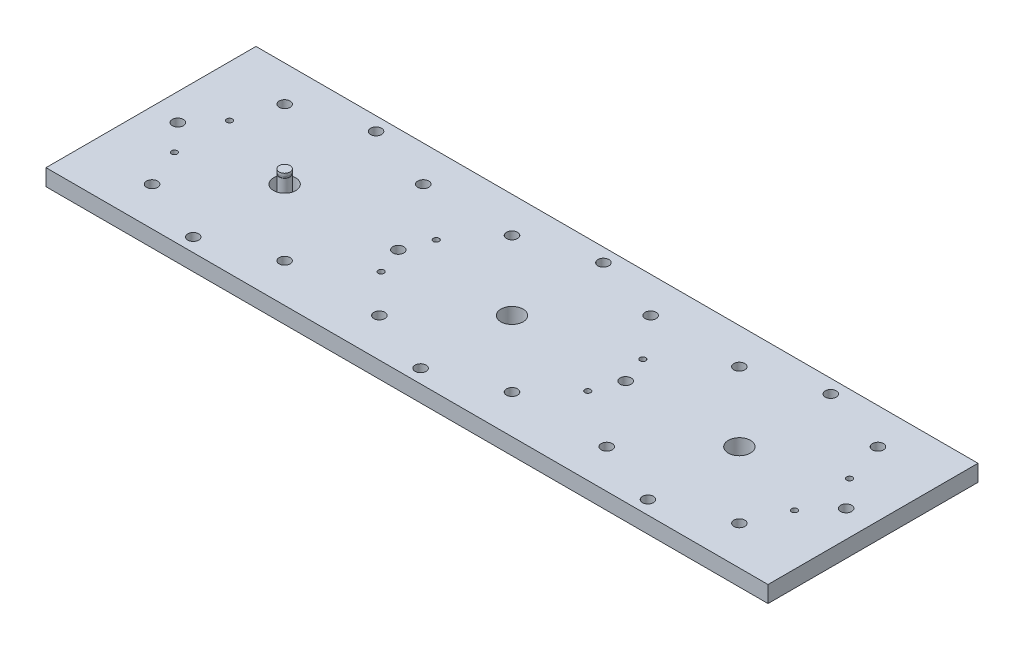
from build123d import *

# Parameters (mm, degrees)
SKETCH1_W                                           = 524
SKETCH1_H                                           = 152.4
SKETCH1_R                                           = 8.05
BOSS_EXTRUDE1_DEPTH                                 = 6
M5_TAPPED_HOLE1_D                                   = 4.2
CBORE_FOR_M4_HEX_SOCKET_HEAD_CAP_SCREW1_D           = 4.5
CBORE_FOR_M4_HEX_SOCKET_HEAD_CAP_SCREW1_CBORE_D     = 8
CBORE_FOR_M4_HEX_SOCKET_HEAD_CAP_SCREW1_CBORE_DEPTH = 9.4


with BuildPart() as part:
    # Sketch1 → Boss-Extrude1 (new body, symmetric)
    with BuildSketch(Plane(origin=(0, 0, 0), x_dir=(1, 0, 0), z_dir=(0, 1, 0))):
        Rectangle(SKETCH1_W, SKETCH1_H)
        with Locations((-165, 0)):
            Circle(SKETCH1_R, mode=Mode.SUBTRACT)
        Circle(SKETCH1_R, mode=Mode.SUBTRACT)
        with Locations((165, 0)):
            Circle(SKETCH1_R, mode=Mode.SUBTRACT)
    extrude(amount=BOSS_EXTRUDE1_DEPTH, both=True)

    # M5 Tapped Hole1 (through all)
    with Locations(Plane(origin=(0, 6, 0), x_dir=(1, 0, 0), z_dir=(0, 1, 0))):
        with Locations((-75, 20), (-225, 20), (-225, -20), (-75, -20), (225, 20), (225, -20), (75, -20), (75, 20)):
            Hole(M5_TAPPED_HOLE1_D / 2)

    # CBORE for M4 Hex Socket Head Cap Screw1 (through all)
    with Locations(Plane(origin=(0, 6, 0), x_dir=(1, 0, 0), z_dir=(0, 1, 0))):
        with Locations((-242.5, 0), (-215.297302762, 50.297302762), (-213.11851323, -48.11851323), (-165, -66.337901802), (-165, 66.338078988), (-114.702697238, 50.297302762), (-116.88148677, -48.11851323), (-82.5, 0), (-48.11851323, -48.11851323), (-50.297302762, 50.297302762), (0, 66.338078988), (0, -66.337901802), (48.11851323, -48.11851323), (50.297302762, 50.297302762), (82.5, 0), (114.702697238, 50.297302762), (116.88148677, -48.11851323), (165, -66.337901802), (165, 66.338078988), (215.297302762, 50.297302762), (213.11851323, -48.11851323), (242.5, 0)):
            CounterBoreHole(CBORE_FOR_M4_HEX_SOCKET_HEAD_CAP_SCREW1_D / 2, CBORE_FOR_M4_HEX_SOCKET_HEAD_CAP_SCREW1_CBORE_D / 2, CBORE_FOR_M4_HEX_SOCKET_HEAD_CAP_SCREW1_CBORE_DEPTH)


with BuildPart() as body_2:
    # Sketch10 → Revolve1 (revolve)
    with BuildSketch(Plane.XY):
        Polygon((-165, -60), (-176, -60), (-176, -57), (-169, -57), (-169, 12.5), (-168.75, 12.5), (-168.75, 13.7), (-169, 13.7), (-169, 15.7), (-165, 15.7), align=None)
    revolve(axis=Axis((-165, 25.832339958, 0), (0, -1, 0)))


solid = Compound([part.part, body_2.part])
